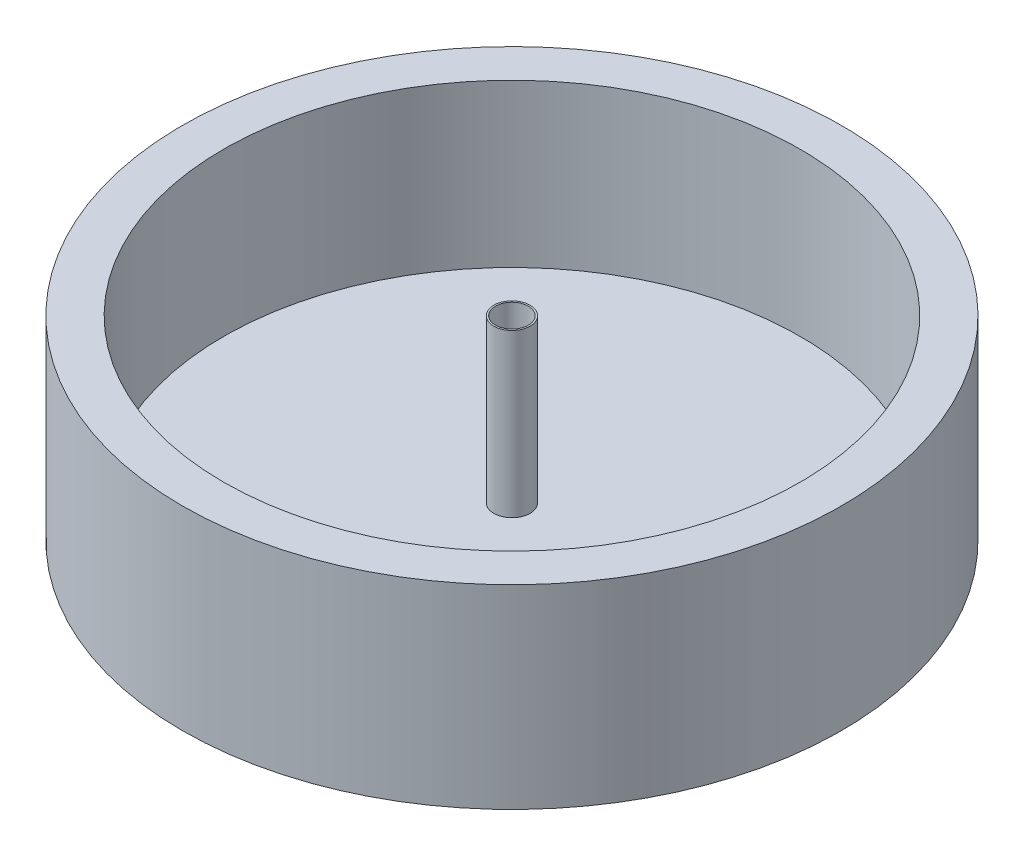
from build123d import *

# Parameters (mm, degrees)
SKETCH1_R           = 50.8
BOSS_EXTRUDE2_DEPTH = 30
SKETCH3_R           = 44.45
CUT_EXTRUDE1_DEPTH  = 25
SKETCH4_R           = 2.794
BOSS_EXTRUDE3_DEPTH = 25
SKETCH5_R           = 2.54
CUT_EXTRUDE2_DEPTH  = 25


with BuildPart() as part:
    # Sketch1 → Boss-Extrude2 (new body)
    with BuildSketch(Plane(origin=(0, 0, 0), x_dir=(1, 0, 0), z_dir=(0, 1, 0))):
        Circle(SKETCH1_R)
    extrude(amount=BOSS_EXTRUDE2_DEPTH)

    # Sketch3 → Cut-Extrude1 (cut)
    with BuildSketch(Plane(origin=(0, 30, 0), x_dir=(1, 0, 0), z_dir=(0, 1, 0))):
        Circle(SKETCH3_R)
    extrude(amount=-CUT_EXTRUDE1_DEPTH, mode=Mode.SUBTRACT)

    # Sketch4 → Boss-Extrude3 (add)
    with BuildSketch(Plane(origin=(0, 5, 0), x_dir=(1, 0, 0), z_dir=(0, 1, 0))):
        Circle(SKETCH4_R)
    extrude(amount=BOSS_EXTRUDE3_DEPTH)

    # Sketch5 → Cut-Extrude2 (cut)
    with BuildSketch(Plane(origin=(0, 30, 0), x_dir=(1, 0, 0), z_dir=(0, 1, 0))):
        Circle(SKETCH5_R)
    extrude(amount=-CUT_EXTRUDE2_DEPTH, mode=Mode.SUBTRACT)


solid = part.part
